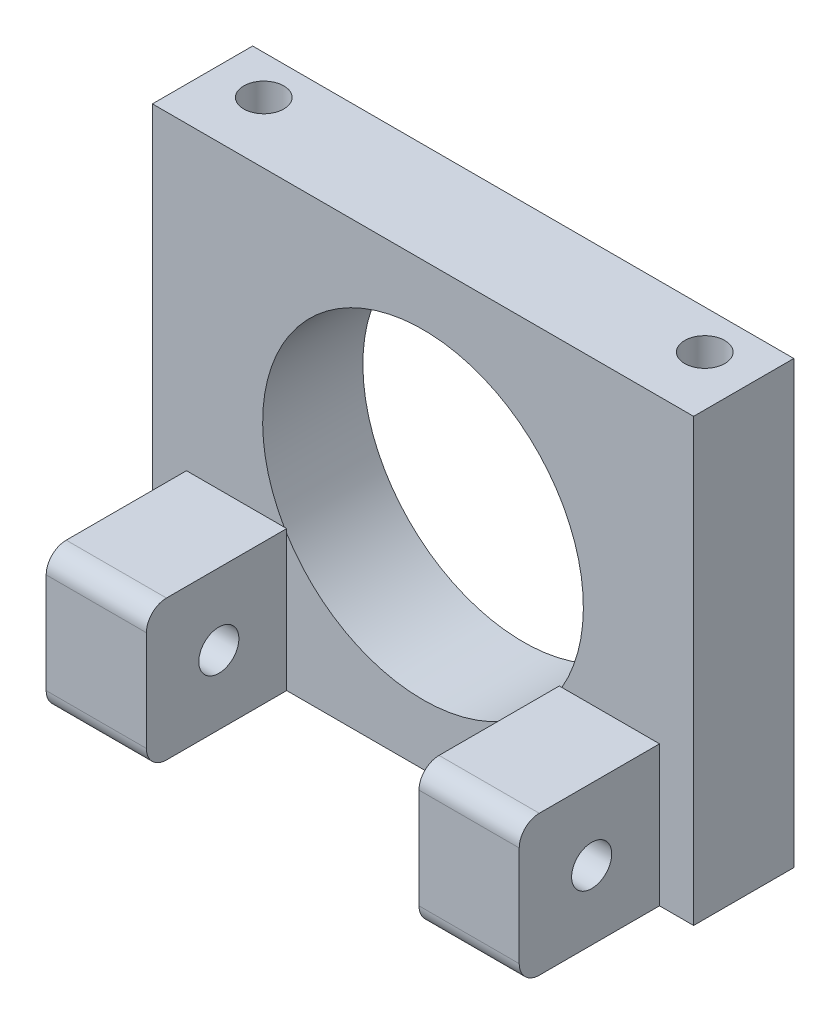
from build123d import *

# Parameters (mm, degrees)
SKETCH1_W           = 27
SKETCH1_H           = 22
SKETCH1_R           = 8
BOSS_EXTRUDE1_DEPTH = 5
SKETCH2_W           = 5
SKETCH2_H           = 7
BOSS_EXTRUDE2_DEPTH = 7
SKETCH3_R           = 1
CUT_EXTRUDE1_DEPTH  = 26.3
FILLET1_R           = 1
SKETCH4_R           = 1
CUT_EXTRUDE2_DEPTH  = 23


with BuildPart() as part:
    # Sketch1 → Boss-Extrude1 (new body)
    with BuildSketch(Plane.XY):
        Rectangle(SKETCH1_W, SKETCH1_H)
        Circle(SKETCH1_R, mode=Mode.SUBTRACT)
    extrude(amount=BOSS_EXTRUDE1_DEPTH)

    # Sketch2 → Boss-Extrude2 (add)
    with BuildSketch(Plane.XY.offset(5)):
        with Locations((-9.3, -7.5)):
            Rectangle(SKETCH2_W, SKETCH2_H)
        with Locations((9.3, -7.5)):
            Rectangle(SKETCH2_W, SKETCH2_H)
    extrude(amount=BOSS_EXTRUDE2_DEPTH)

    # Sketch3 → Cut-Extrude1 (cut, through all)
    with BuildSketch(Plane.ZY.offset(11.8)):
        with Locations((8.386176527, -7.561390553)):
            Circle(SKETCH3_R)
    extrude(amount=-CUT_EXTRUDE1_DEPTH, mode=Mode.SUBTRACT)

    # Fillet1
    fillet1_edges = [part.edges().sort_by_distance(p)[0] for p in [
        (-9.3, -11, 12),
        (-9.3, -4, 12),
        (9.3, -11, 12),
        (9.3, -4, 12),
    ]]
    fillet(fillet1_edges, radius=FILLET1_R)

    # Sketch4 → Cut-Extrude2 (cut, through all)
    with BuildSketch(Plane(origin=(0, 11, 0), x_dir=(1, 0, 0), z_dir=(0, 1, 0))):
        with Locations((-11, -1.944370678)):
            Circle(SKETCH4_R)
        with Locations((11, -1.944370678)):
            Circle(SKETCH4_R)
    extrude(amount=-CUT_EXTRUDE2_DEPTH, mode=Mode.SUBTRACT)


solid = part.part
